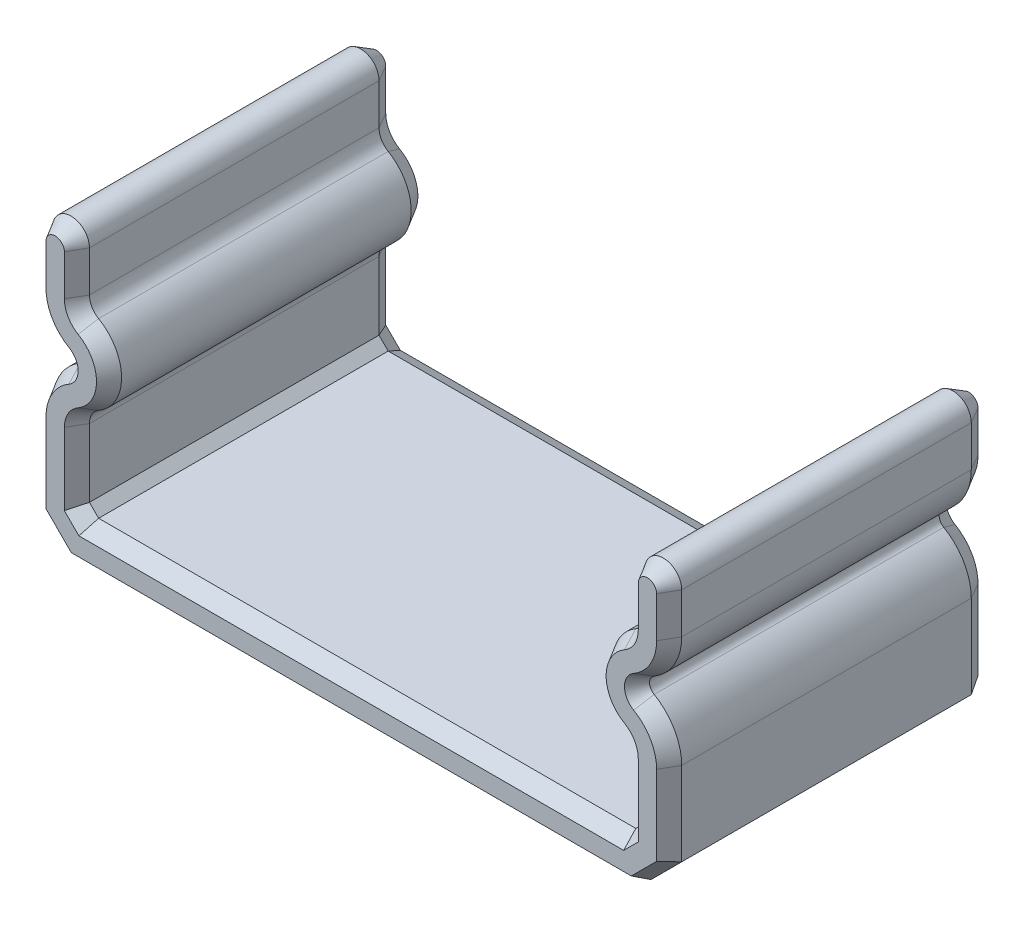
from build123d import *

# Parameters (mm, degrees)
BOSS_EXTRUDE1_DEPTH   = 7
CHAMFER1_SIZE         = 0.2
CHAMFER1_SIZE2        = 0.346410162
CHAMFER1_PART_2_SIZE  = 0.2
CHAMFER1_PART_2_SIZE2 = 0.346410162


with BuildPart() as part:
    # Sketch1 → Boss-Extrude1 (new body)
    with BuildSketch(Plane.XY):
        with BuildLine():
            Line((5.85, 0), (-5.85, 0))
            Line((-5.85, 0), (-6.05, 0.2))
            Line((-6.05, 0.2), (-6.05, 1.687564435))
            ThreePointArc((-6.05, 1.687564435), (-5.996410162, 1.887564435), (-5.85, 2.033974596))
            ThreePointArc((-5.85, 2.033974596), (-5.35, 2.9), (-5.85, 3.766025404))
            ThreePointArc((-5.85, 3.766025404), (-5.996410162, 3.912435565), (-6.05, 4.112435565))
            Line((-6.05, 4.112435565), (-6.05, 5))
            ThreePointArc((-6.05, 5), (-6.45, 5.4), (-6.85, 5))
            Line((-6.85, 5), (-6.85, 4.112435565))
            ThreePointArc((-6.85, 4.112435565), (-6.689230485, 3.512435565), (-6.25, 3.073205081))
            ThreePointArc((-6.25, 3.073205081), (-6.15, 2.9), (-6.25, 2.726794919))
            ThreePointArc((-6.25, 2.726794919), (-6.689230485, 2.287564435), (-6.85, 1.687564435))
            Line((-6.85, 1.687564435), (-6.85, -0.13137085))
            Line((-6.85, -0.13137085), (-6.18137085, -0.8))
            Line((-6.18137085, -0.8), (6.18137085, -0.8))
            Line((6.18137085, -0.8), (6.85, -0.13137085))
            Line((6.85, -0.13137085), (6.85, 1.687564435))
            ThreePointArc((6.85, 1.687564435), (6.689230485, 2.287564435), (6.25, 2.726794919))
            ThreePointArc((6.25, 2.726794919), (6.15, 2.9), (6.25, 3.073205081))
            ThreePointArc((6.25, 3.073205081), (6.689230485, 3.512435565), (6.85, 4.112435565))
            Line((6.85, 4.112435565), (6.85, 5))
            ThreePointArc((6.85, 5), (6.45, 5.4), (6.05, 5))
            Line((6.05, 5), (6.05, 4.112435565))
            ThreePointArc((6.05, 4.112435565), (5.996410162, 3.912435565), (5.85, 3.766025404))
            ThreePointArc((5.85, 3.766025404), (5.35, 2.9), (5.85, 2.033974596))
            ThreePointArc((5.85, 2.033974596), (5.996410162, 1.887564435), (6.05, 1.687564435))
            Line((6.05, 1.687564435), (6.05, 0.2))
            Line((6.05, 0.2), (5.85, 0))
        make_face()
    extrude(amount=BOSS_EXTRUDE1_DEPTH)

    # Chamfer1
    chamfer1_edges = [part.edges().sort_by_distance(p)[0] for p in [
        (5.95, 0.1, 7),
        (0, 0, 7),
        (-5.95, 0.1, 7),
        (-6.05, 0.943782217, 7),
        (-5.996410162, 3.912435565, 7),
        (-6.05, 4.556217783, 7),
        (-6.45, 5.4, 7),
        (-6.85, 4.556217783, 7),
        (-6.689230485, 3.512435565, 7),
        (-6.15, 2.9, 7),
        (-6.689230485, 2.287564435, 7),
        (-6.85, 0.778096792, 7),
        (-6.515685425, -0.465685425, 7),
        (0, -0.8, 7),
        (-5.996410162, 1.887564435, 7),
        (6.515685425, -0.465685425, 7),
        (6.85, 0.778096792, 7),
        (6.689230485, 2.287564435, 7),
        (6.15, 2.9, 7),
        (6.689230485, 3.512435565, 7),
        (6.85, 4.556217783, 7),
        (6.45, 5.4, 7),
        (6.05, 4.556217783, 7),
        (5.996410162, 3.912435565, 7),
        (5.35, 2.9, 7),
        (-5.35, 2.9, 7),
        (5.996410162, 1.887564435, 7),
        (6.05, 0.943782217, 7),
    ]]
    chamfer1_side = [part.faces().sort_by_distance(p)[0] for p in [
        (6.126639766, 1.962752532, 7),
    ]]
    chamfer(chamfer1_edges, length=CHAMFER1_SIZE, length2=CHAMFER1_SIZE2, reference=chamfer1_side[0])

    # Chamfer1 part 2
    chamfer1_part_2_edges = [part.edges().sort_by_distance(p)[0] for p in [
        (-6.05, 0.943782217, 0),
        (-5.95, 0.1, 0),
        (0, 0, 0),
        (5.95, 0.1, 0),
        (6.05, 0.943782217, 0),
        (5.996410162, 1.887564435, 0),
        (5.35, 2.9, 0),
        (5.996410162, 3.912435565, 0),
        (6.05, 4.556217783, 0),
        (6.45, 5.4, 0),
        (6.85, 4.556217783, 0),
        (6.689230485, 3.512435565, 0),
        (6.15, 2.9, 0),
        (6.689230485, 2.287564435, 0),
        (6.85, 0.778096792, 0),
        (6.515685425, -0.465685425, 0),
        (0, -0.8, 0),
        (-6.515685425, -0.465685425, 0),
        (-6.85, 0.778096792, 0),
        (-6.689230485, 2.287564435, 0),
        (-6.15, 2.9, 0),
        (-6.689230485, 3.512435565, 0),
        (-6.85, 4.556217783, 0),
        (-6.45, 5.4, 0),
        (-6.05, 4.556217783, 0),
        (-5.996410162, 3.912435565, 0),
        (-5.35, 2.9, 0),
        (-5.996410162, 1.887564435, 0),
    ]]
    chamfer1_part_2_side = [part.faces().sort_by_distance(p)[0] for p in [
        (6.126639766, 1.962752532, 0),
    ]]
    chamfer(chamfer1_part_2_edges, length=CHAMFER1_PART_2_SIZE, length2=CHAMFER1_PART_2_SIZE2, reference=chamfer1_part_2_side[0])


solid = part.part
